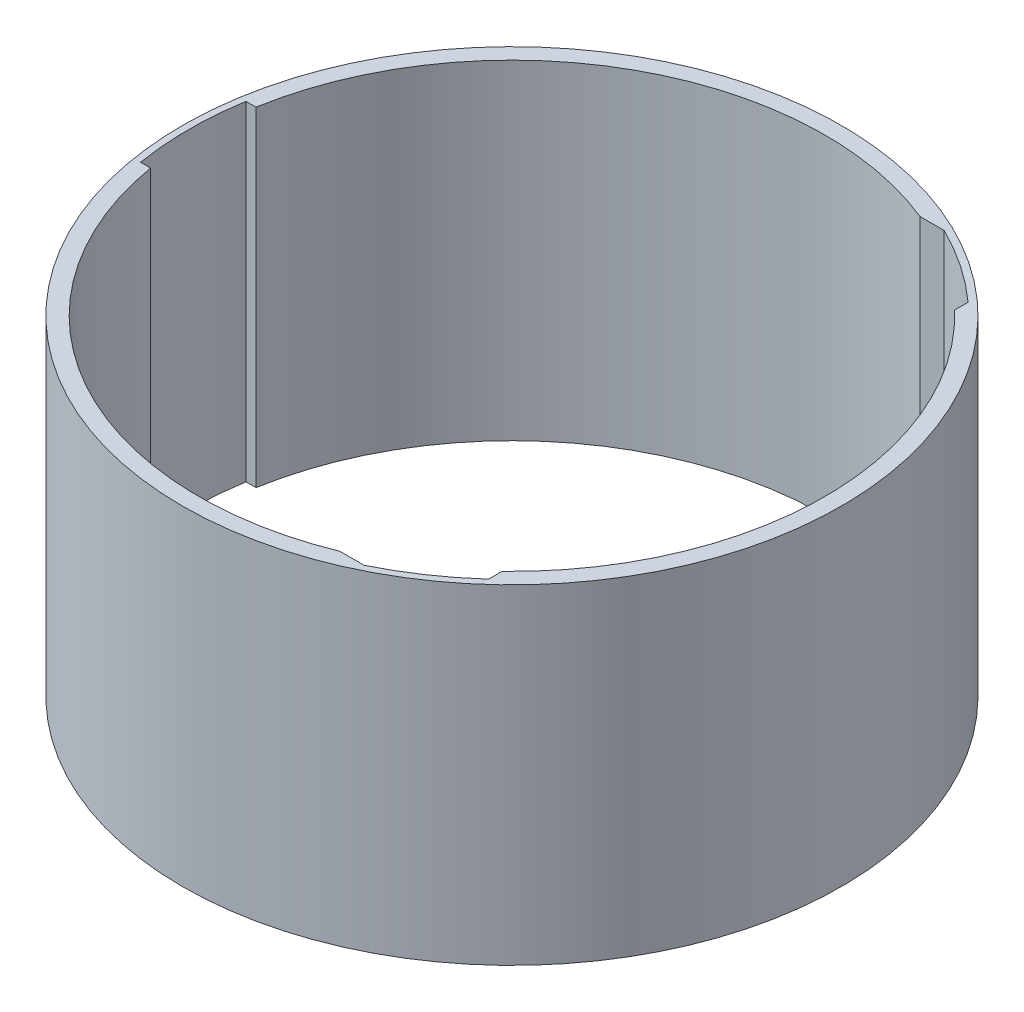
from build123d import *

# Parameters (mm, degrees)
SKETCH1_R           = 100
SKETCH1_R_2         = 95
BOSS_EXTRUDE1_DEPTH = 100
CUT_EXTRUDE1_DEPTH  = 101


with BuildPart() as part:
    # Sketch1 → Boss-Extrude1 (new body)
    with BuildSketch(Plane(origin=(0, 0, 0), x_dir=(1, 0, 0), z_dir=(0, 1, 0))):
        Circle(SKETCH1_R)
        Circle(SKETCH1_R_2, mode=Mode.SUBTRACT)
    extrude(amount=BOSS_EXTRUDE1_DEPTH)

    # Sketch2 → Cut-Extrude1 (cut, through all)
    with BuildSketch(Plane(origin=(0, 100, 0), x_dir=(1, 0, 0), z_dir=(0, 1, 0))):
        with BuildLine():
            ThreePointArc((65.656830535, 72.754248014), (54.935999613, 81.154395731), (43.154094517, 87.98706795))
            Line((43.154094517, 87.98706795), (35.82284011, 87.98706795))
            ThreePointArc((35.82284011, 87.98706795), (51.651871532, 79.731324881), (65.656830535, 68.659890795))
            Line((65.656830535, 68.659890795), (65.656830535, 72.754248014))
        make_face()
        with BuildLine():
            ThreePointArc((43.154094517, -87.98706795), (54.935999613, -81.154395731), (65.656830535, -72.754248014))
            Line((65.656830535, -72.754248014), (65.656830535, -68.659890795))
            ThreePointArc((65.656830535, -68.659890795), (51.651871532, -79.731324881), (35.82284011, -87.98706795))
            Line((35.82284011, -87.98706795), (43.154094517, -87.98706795))
        make_face()
        with BuildLine():
            Line((-93.642938869, 16), (-96.685055722, 16))
            ThreePointArc((-96.685055722, 16), (-98, 0), (-96.685055722, -16))
            Line((-96.685055722, -16), (-93.642938869, -16))
            ThreePointArc((-93.642938869, -16), (-95, 0), (-93.642938869, 16))
        make_face()
    extrude(amount=-CUT_EXTRUDE1_DEPTH, mode=Mode.SUBTRACT)


solid = part.part
